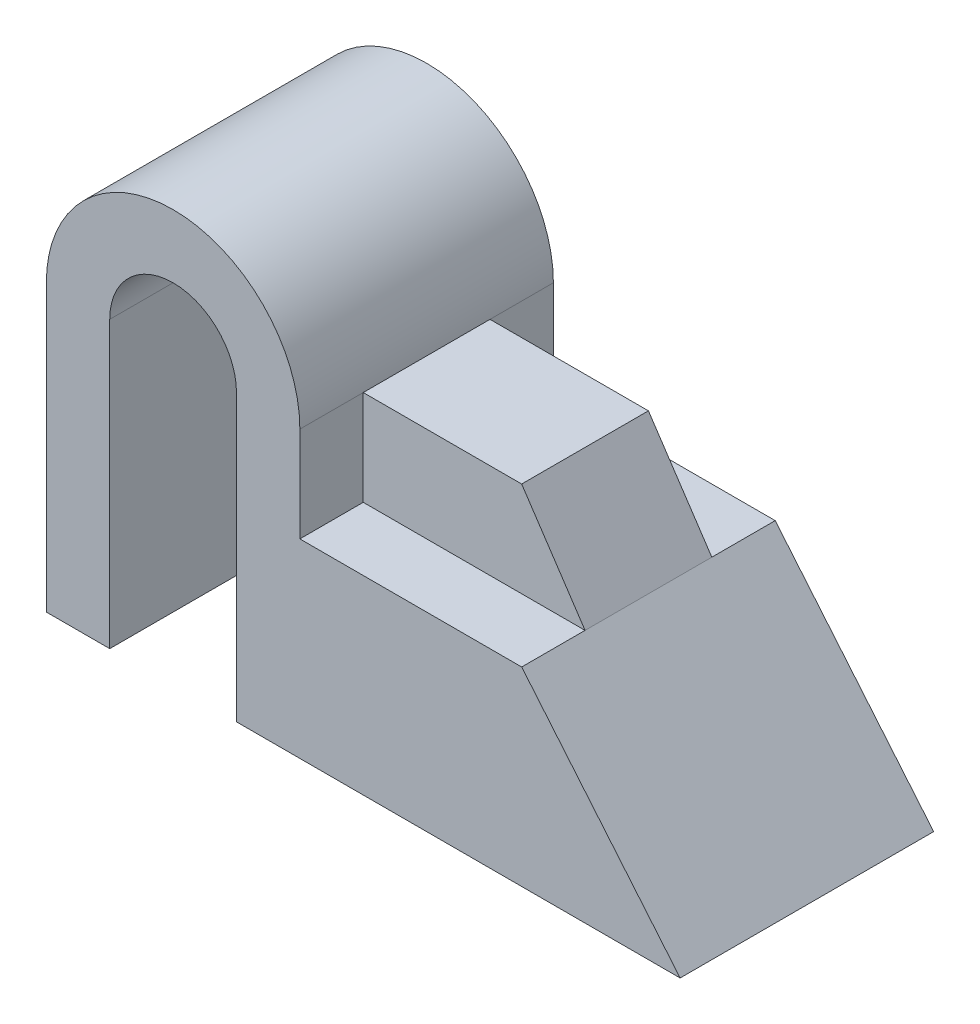
from build123d import *

# Parameters (mm, degrees)
BOSS_EXTRUDE1_DEPTH = 20
BOSS_EXTRUDE2_DEPTH = 10
CUT_EXTRUDE1_DEPTH  = 20


with BuildPart() as part:
    # Sketch1 → Boss-Extrude1 (new body, symmetric)
    with BuildSketch(Plane.XY):
        with BuildLine():
            Line((0, 0), (100, 0))
            Line((100, 0), (75, 30))
            Line((75, 30), (40, 30))
            Line((40, 30), (40, 45))
            ThreePointArc((40, 45), (34.142135624, 59.142135624), (20, 65))
            ThreePointArc((20, 65), (5.857864376, 59.142135624), (0, 45))
            Line((0, 45), (0, 0))
        make_face()
    extrude(amount=BOSS_EXTRUDE1_DEPTH, both=True)

    # Sketch2 → Boss-Extrude2 (add, symmetric)
    with BuildSketch(Plane.XY):
        Polygon((40, 30), (40, 45), (64.995844506, 45), (75, 30), align=None)
    extrude(amount=BOSS_EXTRUDE2_DEPTH, both=True)

    # Sketch3 → Cut-Extrude1 (cut, symmetric)
    with BuildSketch(Plane.XY):
        with BuildLine():
            Line((10, 0), (10, 45))
            ThreePointArc((10, 45), (20, 55), (30, 45))
            Line((30, 45), (30, 0))
            Line((30, 0), (10, 0))
        make_face()
    extrude(amount=CUT_EXTRUDE1_DEPTH, both=True, mode=Mode.SUBTRACT)


solid = part.part
